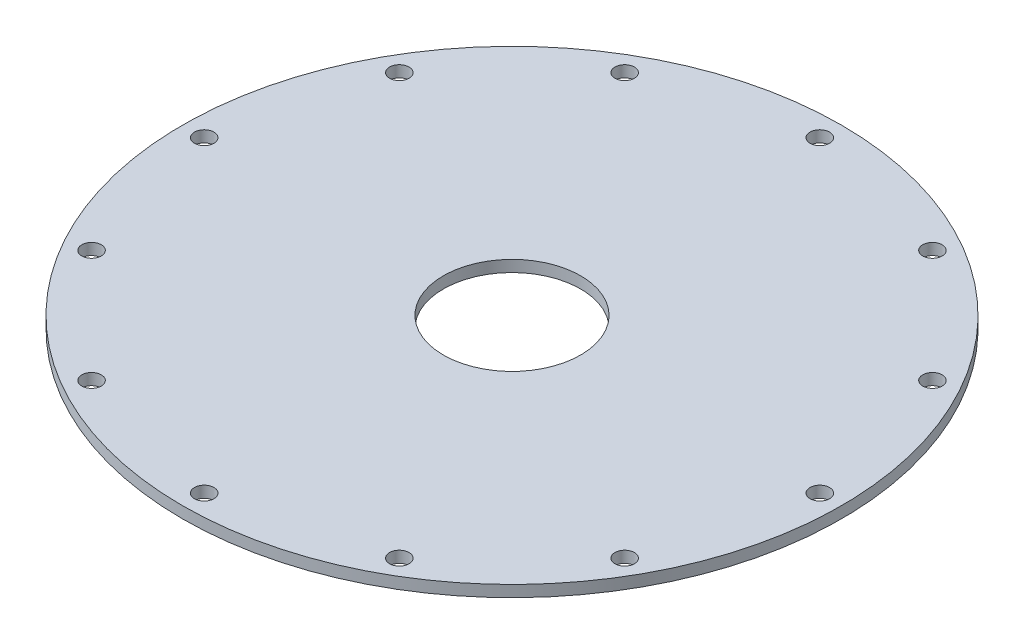
from build123d import *

# Parameters (mm, degrees)
SKETCH1_W                    = 36.195
SKETCH1_H                    = 1.5875
F_36_0_1065_DIAMETER_HOLE1_D = 2.7051
CIRPATTERN1_COUNT            = 12


with BuildPart() as part:
    # Sketch1 → Revolve1 (revolve)
    with BuildSketch(Plane.XY):
        with Locations((-27.6225, 0.79375)):
            Rectangle(SKETCH1_W, SKETCH1_H)
    revolve(axis=Axis((0, 55, 0), (0, -1, 0)))

    # #36 (0.1065) Diameter Hole1 (through all)
    with Locations(Plane(origin=(0, 1.5875, 0), x_dir=(1, 0, 0), z_dir=(0, 1, 0))):
        with Locations((-42.700575, 0)):
            f_36_0_1065_diameter_hole1 = Hole(F_36_0_1065_DIAMETER_HOLE1_D / 2)

    # CirPattern1: #36 (0.1065) Diameter Hole1 ×12 about axis
    cirpattern1_axis = Axis((0, 0, 0), (0, 1, 0))
    for i in range(1, CIRPATTERN1_COUNT):
        add(f_36_0_1065_diameter_hole1.rotate(cirpattern1_axis, i * 360 / CIRPATTERN1_COUNT), mode=Mode.SUBTRACT)


solid = part.part
